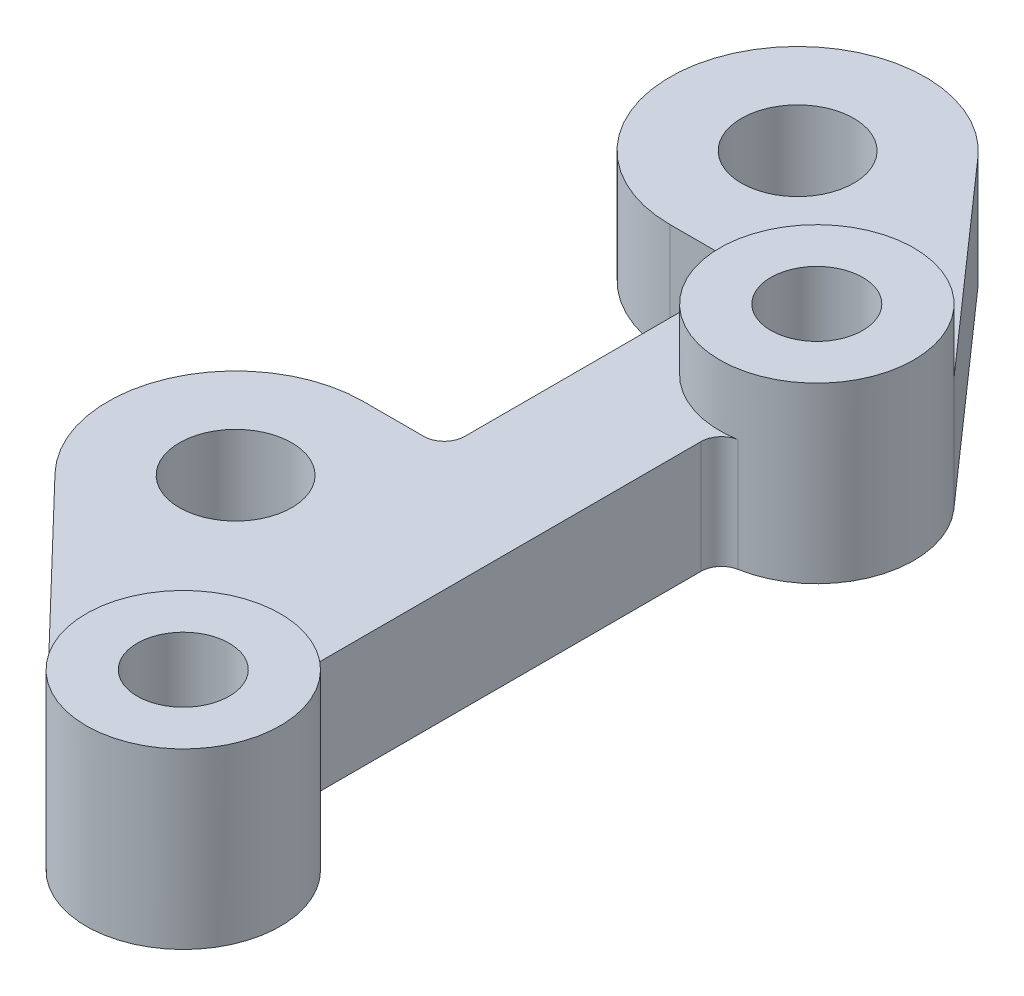
from build123d import *

# Parameters (mm, degrees)
ESQUISSE1_R        = 4.5
ESQUISSE1_R_2      = 5.5
BOSS_EXTRU_1_DEPTH = 11
ESQUISSE3_R        = 9.5
ESQUISSE3_R_2      = 4.5
BOSS_EXTRU_3_DEPTH = 6


with BuildPart() as part:
    # Esquisse1 → Boss.-Extru.1 (new body)
    with BuildSketch(Plane(origin=(0, 0, 0), x_dir=(1, 0, 0), z_dir=(0, 1, 0))):
        with BuildLine():
            Line((-28.930476165, 16.379180347), (-6.847605923, -6.584853311))
            ThreePointArc((-6.847605923, -6.584853311), (8.382701799, -4.469934065), (1.652173913, 9.355229626))
            ThreePointArc((1.652173913, 9.355229626), (0.467738245, 10.039382479), (0, 11.324751653))
            Line((0, 11.324751653), (0, 50.675248347))
            ThreePointArc((0, 50.675248347), (0.467738245, 51.960617521), (1.652173913, 52.644770374))
            ThreePointArc((1.652173913, 52.644770374), (8.967130897, 58.863032758), (7.12365328, 68.285186071))
            Line((7.12365328, 68.285186071), (-10.547240372, 88.313442691))
            ThreePointArc((-10.547240372, 88.313442691), (-31.313992211, 85.185213109), (-19.920468372, 67.543461019))
            Line((-19.920468372, 67.543461019), (-14, 67.543461019))
            ThreePointArc((-14, 67.543461019), (-12.585786438, 66.957674582), (-12, 65.543461019))
            Line((-12, 65.543461019), (-12, 39.543461019))
            ThreePointArc((-12, 39.543461019), (-12.585786438, 38.129247457), (-14, 37.543461019))
            Line((-14, 37.543461019), (-19.920468372, 37.543461019))
            ThreePointArc((-19.920468372, 37.543461019), (-31.42163154, 29.939709154), (-28.930476165, 16.379180347))
        make_face()
        with Locations(Location((0, 0, 0), (0, 0, 270))):  # turned: the seam where the file's is
            Circle(ESQUISSE1_R, mode=Mode.SUBTRACT)
        with Locations(Location((-19.920468372, 25.043461019, 0), (0, 0, 270))):  # turned: the seam where the file's is
            Circle(ESQUISSE1_R_2, mode=Mode.SUBTRACT)
        with Locations(Location((0, 62, 0), (0, 0, 270))):  # turned: the seam where the file's is
            Circle(ESQUISSE1_R, mode=Mode.SUBTRACT)
        with Locations(Location((-19.920468372, 80.043461019, 0), (0, 0, 270))):  # turned: the seam where the file's is
            Circle(ESQUISSE1_R_2, mode=Mode.SUBTRACT)
    extrude(amount=BOSS_EXTRU_1_DEPTH)

    # Esquisse3 → Boss.-Extru.3 (add)
    with BuildSketch(Plane(origin=(0, 11, 0), x_dir=(1, 0, 0), z_dir=(0, 1, 0))):
        with Locations(Location((0, 0, 0), (0, 0, 79.984589832))):  # turned: the seam where the file's is
            Circle(ESQUISSE3_R)
        with Locations(Location((0, 0, 0), (0, 0, 270))):  # turned: the seam where the file's is
            Circle(ESQUISSE3_R_2, mode=Mode.SUBTRACT)
        with Locations(Location((0, 62, 0), (0, 0, 41.421900303))):  # turned: the seam where the file's is
            Circle(ESQUISSE3_R)
        with Locations(Location((0, 62, 0), (0, 0, 270))):  # turned: the seam where the file's is
            Circle(ESQUISSE3_R_2, mode=Mode.SUBTRACT)
    extrude(amount=BOSS_EXTRU_3_DEPTH)


solid = part.part
